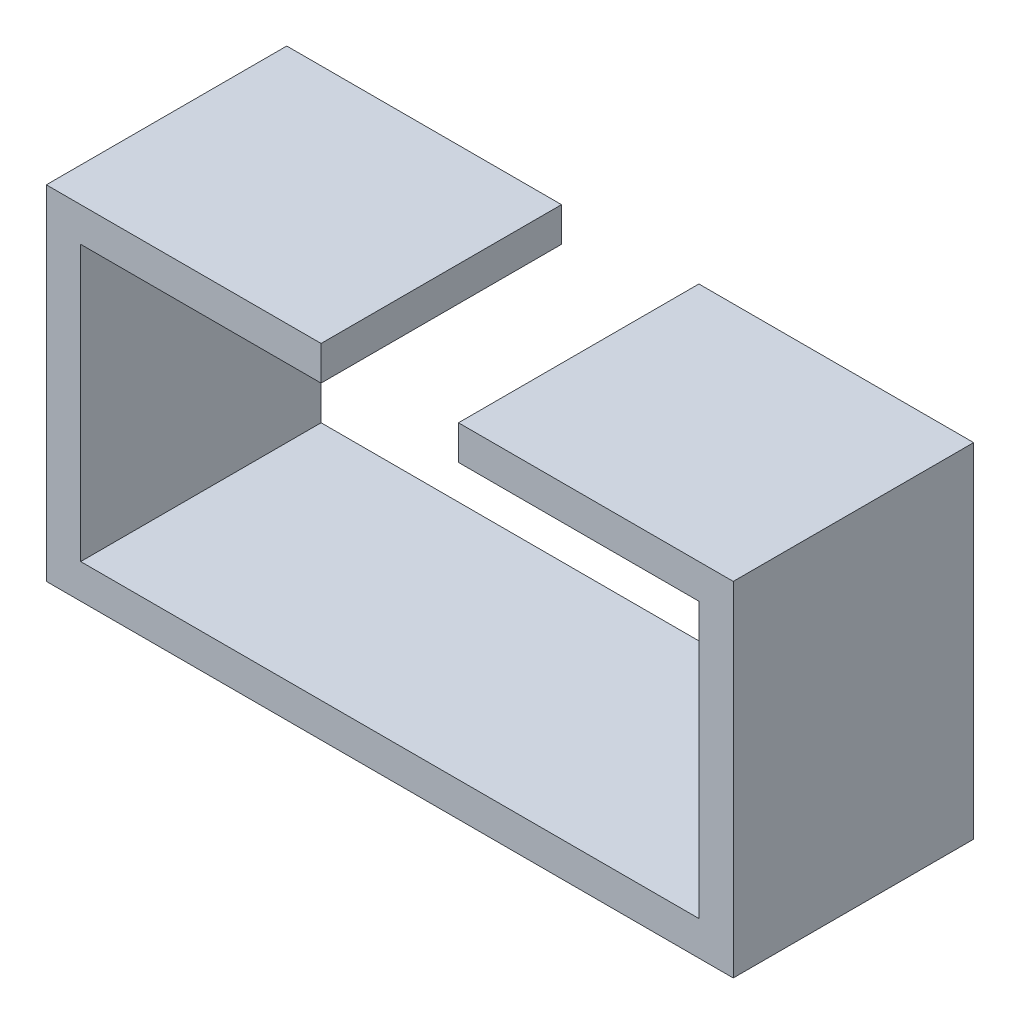
from build123d import *

# Parameters (mm, degrees)
BOSS_EXTRUDE1_DEPTH = 17.78


with BuildPart() as part:
    # Sketch1 → Boss-Extrude1 (new body)
    with BuildSketch(Plane.XY):
        Polygon((-22.86, 10.16), (-5.08, 10.16), (-5.08, 12.7), (-25.4, 12.7), (-25.4, -12.7), (25.4, -12.7), (25.4, 12.7), (5.08, 12.7), (5.08, 10.16), (22.86, 10.16), (22.86, -10.16), (-22.86, -10.16), align=None)
    extrude(amount=BOSS_EXTRUDE1_DEPTH)


solid = part.part
